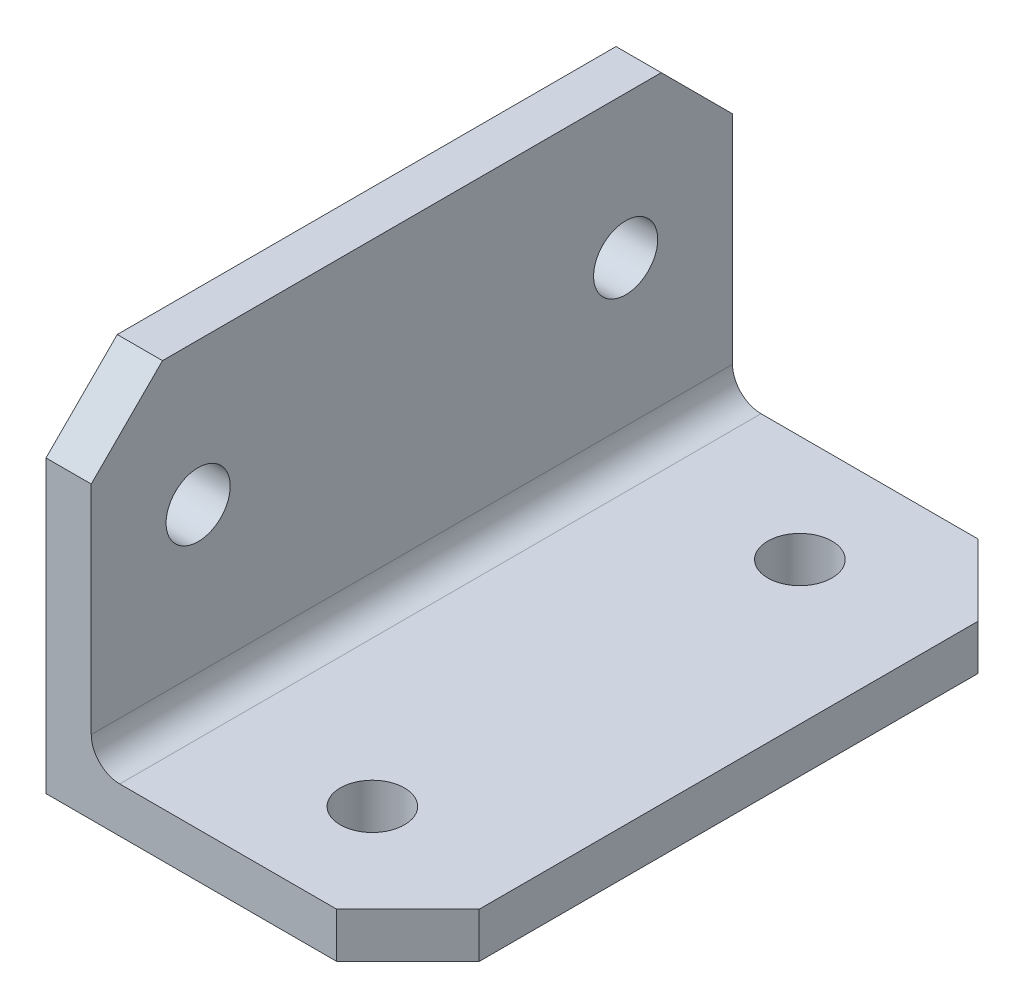
from build123d import *

# Parameters (mm, degrees)
BOSS_EXTRUDE1_DEPTH  = 22.5
M4_CLEARANCE_HOLE1_D = 4.5
M4_CLEARANCE_HOLE2_D = 4.5
FILLET1_R            = 2
CHAMFER1_SIZE        = 5


with BuildPart() as part:
    # Sketch1 → Boss-Extrude1 (new body, symmetric)
    with BuildSketch(Plane.XY):
        Polygon((0, 0), (0, 25.4), (3.175, 25.4), (3.175, 3.175), (25.4, 3.175), (25.4, 0), align=None)
    extrude(amount=BOSS_EXTRUDE1_DEPTH, both=True)

    # M4 Clearance Hole1 (through all)
    with Locations(Plane(origin=(0, 3.175, 0), x_dir=(1, 0, 0), z_dir=(0, 1, 0))):
        with Locations((15.4, 15), (15.4, -15)):
            Hole(M4_CLEARANCE_HOLE1_D / 2)

    # M4 Clearance Hole2 (through all)
    with Locations(Plane(origin=(3.175, 0, 0), x_dir=(0, 0, -1), z_dir=(1, 0, 0))):
        with Locations((-15, 15.4), (15, 15.4)):
            Hole(M4_CLEARANCE_HOLE2_D / 2)

    # Fillet1
    fillet1_edges = [part.edges().sort_by_distance(p)[0] for p in [
        (3.175, 3.175, 0),
    ]]
    fillet(fillet1_edges, radius=FILLET1_R)

    # Chamfer1
    chamfer1_edges = [part.edges().sort_by_distance(p)[0] for p in [
        (1.5875, 25.4, 22.5),
        (1.5875, 25.4, -22.5),
        (25.4, 1.5875, -22.5),
        (25.4, 1.5875, 22.5),
    ]]
    chamfer(chamfer1_edges, length=CHAMFER1_SIZE)


solid = part.part
